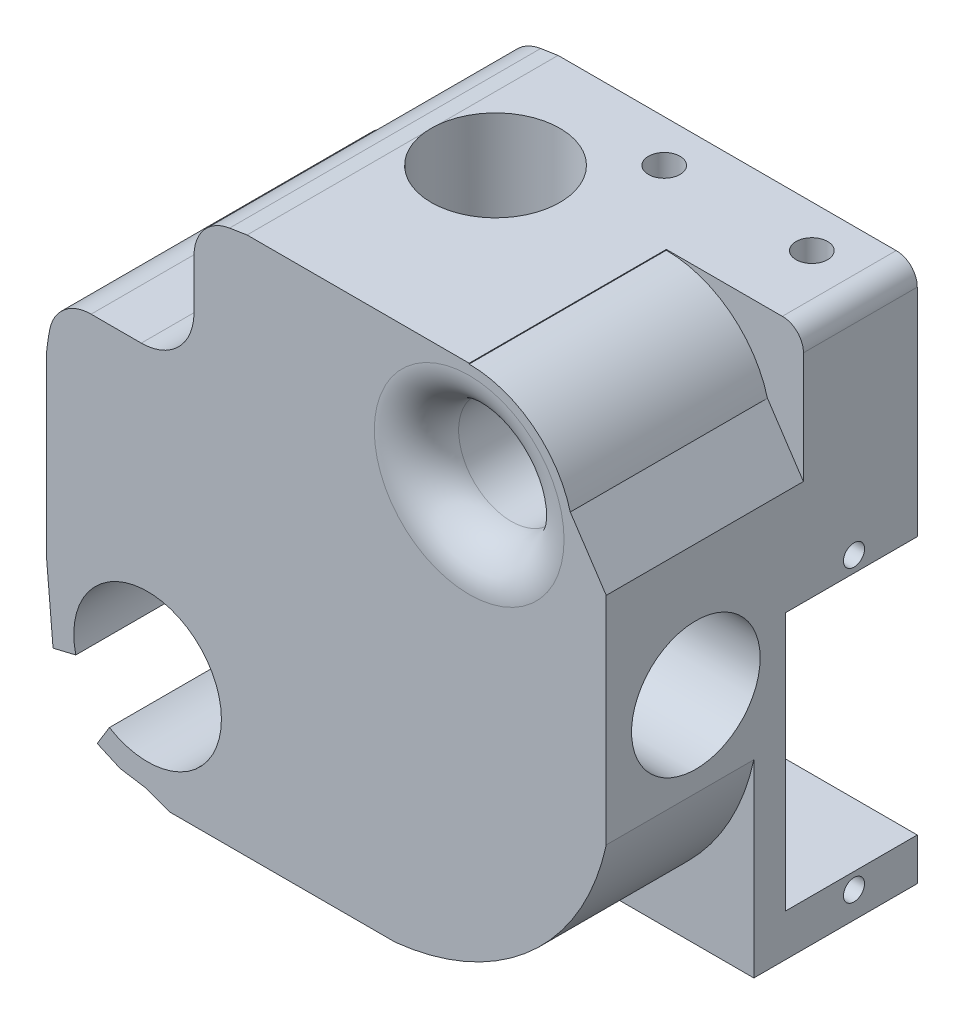
from build123d import *

# Parameters (mm, degrees)
SALIENTE_EXTRUIR1_DEPTH = 29.5
CORTAR_EXTRUIR11_DEPTH  = 18.7
CROQUIS12_W             = 20
CROQUIS12_H             = 28.5
SALIENTE_EXTRUIR2_DEPTH = 15.5
CROQUIS6_R              = 8.5
CORTAR_EXTRUIR1_DEPTH   = 10
CROQUIS7_R              = 4.1
CORTAR_EXTRUIR2_DEPTH   = 13.5
CROQUIS8_R              = 4.4
CORTAR_EXTRUIR3_DEPTH   = 6
CROQUIS2_R              = 6.1
CORTAR_EXTRUIR4_DEPTH   = 20
CROQUIS3_R              = 6.1
CORTAR_EXTRUIR5_DEPTH   = 20
CROQUIS4_R              = 6.1
CORTAR_EXTRUIR6_DEPTH   = 20
CROQUIS5_R              = 6.1
CORTAR_EXTRUIR7_DEPTH   = 20
CORTAR_EXTRUIR8_REACH   = 35.067
CROQUIS9_R              = 3.5
CORTAR_EXTRUIR9_REACH   = 33.068
CROQUIS10_R             = 3.5
CROQUIS13_W             = 20
CROQUIS13_H             = 24.5
CORTAR_EXTRUIR10_DEPTH  = 12.5
CORTAR_EXTRUIR12_START  = -10
CROQUIS18_R             = 1.5
CORTAR_EXTRUIR12_DEPTH  = 10
CROQUIS19_R             = 1
CORTAR_EXTRUIR13_DEPTH  = 10
CROQUIS20_R             = 2.1
CORTAR_EXTRUIR14_DEPTH  = 10
CROQUIS21_R             = 5
CORTAR_EXTRUIR15_DEPTH  = 50
CROQUIS23_W             = 16.524922623
CROQUIS23_H             = 14.423778161
CORTAR_EXTRUIR16_DEPTH  = 50
REDONDEO1_R             = 4
REDONDEO2_R             = 5
REDONDEO3_R             = 4


with BuildPart() as part:
    # Croquis1 → Saliente-Extruir1 (new body)
    with BuildSketch(Plane.XY):
        with BuildLine():
            Line((5.532260486, 11.858052865), (4.932758535, 18.779017183))
            Line((4.932758535, 18.779017183), (4.932758535, 36))
            ThreePointArc((4.932758535, 36), (10.243586381, 47.979347327), (21.538526154, 54.62268913))
            Line((21.538526154, 54.62268913), (23.932758535, 55))
            Line((23.932758535, 55), (56, 55))
            ThreePointArc((56, 55), (57.424264069, 54.424264069), (58, 53))
            Line((58, 53), (58, 21.932758535))
            ThreePointArc((58, 21.932758535), (50.913097547, 9.695983483), (38, 3.932758535))
            Line((38, 3.932758535), (16.641947135, 3.932758535))
            Line((16.641947135, 3.932758535), (14.26534365, 4.78116089))
            Line((14.26534365, 4.78116089), (11.904731608, 5.153727551))
            Line((11.904731608, 5.153727551), (9.720982817, 6.124570664))
            Line((9.720982817, 6.124570664), (10.875746205, 8.011278565))
            ThreePointArc((10.875746205, 8.011278565), (20.155175368, 18.125408047), (7.690637501, 12.377476547))
            Line((7.690637501, 12.377476547), (5.532260486, 11.858052865))
        make_face()
    extrude(amount=-SALIENTE_EXTRUIR1_DEPTH)

    # Croquis15 → Cortar-Extruir11 (cut)
    with BuildSketch(Plane.XY):
        with BuildLine():
            Line((58, 42.430465887), (58, 53))
            ThreePointArc((58, 53), (57.424264069, 54.424264069), (56, 55))
            Line((56, 55), (45, 55))
            Line((45, 55), (45, 54.927917446))
            ThreePointArc((45, 54.927917446), (51.043733212, 52.876346468), (54.589631863, 47.569534113))
            Line((54.589631863, 47.569534113), (58, 42.430465887))
        make_face()
    extrude(amount=-CORTAR_EXTRUIR11_DEPTH, mode=Mode.SUBTRACT)

    # Croquis12 → Saliente-Extruir2 (add)
    with BuildSketch(Plane(origin=(0, 0, -29.5), x_dir=(-1, 0, 0), z_dir=(0, 0, -1))):
        with Locations((-48, 18.25)):
            Rectangle(CROQUIS12_W, CROQUIS12_H)
    extrude(amount=-SALIENTE_EXTRUIR2_DEPTH)

    # Croquis6 → Cortar-Extruir1 (cut)
    with BuildSketch(Plane(origin=(0, 0, -29.5), x_dir=(-1, 0, 0), z_dir=(0, 0, -1))):
        with Locations((-45, 45)):
            Circle(CROQUIS6_R)
    extrude(amount=-CORTAR_EXTRUIR1_DEPTH, mode=Mode.SUBTRACT)

    # Croquis7 → Cortar-Extruir2 (cut)
    with BuildSketch(Plane(origin=(0, 0, -19.5), x_dir=(-1, 0, 0), z_dir=(0, 0, -1))):
        with Locations((-45, 45)):
            Circle(CROQUIS7_R)
    extrude(amount=-CORTAR_EXTRUIR2_DEPTH, mode=Mode.SUBTRACT)

    # Croquis8 → Cortar-Extruir3 (cut)
    with BuildSketch(Plane.XY):
        with Locations((45, 45)):
            Circle(CROQUIS8_R)
    extrude(amount=-CORTAR_EXTRUIR3_DEPTH, mode=Mode.SUBTRACT)

    # Croquis2 → Cortar-Extruir4 (cut)
    with BuildSketch(Plane.XZ.offset(-3.932758535)):
        with Locations((30, -17.5)):
            Circle(CROQUIS2_R)
    extrude(amount=-CORTAR_EXTRUIR4_DEPTH, mode=Mode.SUBTRACT)

    # Croquis3 → Cortar-Extruir5 (cut)
    with BuildSketch(Plane(origin=(0, 55, 0), x_dir=(1, 0, 0), z_dir=(0, 1, 0))):
        with Locations((30, 17.5)):
            Circle(CROQUIS3_R)
    extrude(amount=-CORTAR_EXTRUIR5_DEPTH, mode=Mode.SUBTRACT)

    # Croquis4 → Cortar-Extruir6 (cut)
    with BuildSketch(Plane.ZY.offset(-4.932758535)):
        with Locations((-8.5, 30)):
            Circle(CROQUIS4_R)
    extrude(amount=-CORTAR_EXTRUIR6_DEPTH, mode=Mode.SUBTRACT)

    # Croquis5 → Cortar-Extruir7 (cut)
    with BuildSketch(Plane(origin=(58, 0, 0), x_dir=(0, 0, -1), z_dir=(1, 0, 0))):
        with Locations((8.5, 30)):
            Circle(CROQUIS5_R)
    extrude(amount=-CORTAR_EXTRUIR7_DEPTH, mode=Mode.SUBTRACT)

    # Croquis9 → Cortar-Extruir8 (cut, up to next)
    with BuildSketch(Plane(origin=(38, 0, 0), x_dir=(0, 0, -1), z_dir=(1, 0, 0)), mode=Mode.PRIVATE) as cortar_extruir8_sk1:
        with Locations((8.5, 30)):
            Circle(CROQUIS9_R)
    cortar_extruir8_tool1 = extrude(cortar_extruir8_sk1.sketch, amount=-CORTAR_EXTRUIR8_REACH, mode=Mode.PRIVATE) & part.part
    add(cortar_extruir8_tool1.solids().sort_by_distance((38, 30, -8.5))[0], mode=Mode.SUBTRACT)

    # Croquis10 → Cortar-Extruir9 (cut, up to next)
    with BuildSketch(Plane.XZ.offset(-23.932758535), mode=Mode.PRIVATE) as cortar_extruir9_sk1:
        with Locations((30, -17.5)):
            Circle(CROQUIS10_R)
    cortar_extruir9_tool1 = extrude(cortar_extruir9_sk1.sketch, amount=-CORTAR_EXTRUIR9_REACH, mode=Mode.PRIVATE) & part.part
    add(cortar_extruir9_tool1.solids().sort_by_distance((30, 23.932759, -17.5))[0], mode=Mode.SUBTRACT)

    # Croquis13 → Cortar-Extruir10 (cut)
    with BuildSketch(Plane(origin=(0, 0, -29.5), x_dir=(-1, 0, 0), z_dir=(0, 0, -1))):
        with Locations((-48, 20.25)):
            Rectangle(CROQUIS13_W, CROQUIS13_H)
    extrude(amount=-CORTAR_EXTRUIR10_DEPTH, mode=Mode.SUBTRACT)

    # Croquis18 → Cortar-Extruir12 (cut)
    with BuildSketch(Plane(origin=(0, 55, 0), x_dir=(1, 0, 0), z_dir=(0, 1, 0)).offset(CORTAR_EXTRUIR12_START)):
        with Locations((38.000000773, 25.50000943)):
            Circle(CROQUIS18_R)
        with Locations((52.000000773, 25.50000943)):
            Circle(CROQUIS18_R)
    extrude(amount=CORTAR_EXTRUIR12_DEPTH, mode=Mode.SUBTRACT)

    # Croquis19 → Cortar-Extruir13 (cut)
    with BuildSketch(Plane(origin=(58, 0, 0), x_dir=(0, 0, -1), z_dir=(1, 0, 0))):
        with Locations((23.5, 34)):
            Circle(CROQUIS19_R)
        with Locations((23.5, 6.5)):
            Circle(CROQUIS19_R)
    extrude(amount=-CORTAR_EXTRUIR13_DEPTH, mode=Mode.SUBTRACT)

    # Croquis20 → Cortar-Extruir14 (cut)
    with BuildSketch(Plane(origin=(0, 0, -29.5), x_dir=(-1, 0, 0), z_dir=(0, 0, -1))):
        with Locations((-16, 36)):
            Circle(CROQUIS20_R)
    extrude(amount=-CORTAR_EXTRUIR14_DEPTH, mode=Mode.SUBTRACT)

    # Croquis21 → Cortar-Extruir15 (cut)
    with BuildSketch(Plane.XY):
        with Locations((45, 45)):
            Circle(CROQUIS21_R)
    extrude(amount=-CORTAR_EXTRUIR15_DEPTH, mode=Mode.SUBTRACT)

    # Croquis23 → Cortar-Extruir16 (cut)
    with BuildSketch(Plane.XY):
        with Locations((10.637538689, 48.311889081)):
            Rectangle(CROQUIS23_W, CROQUIS23_H)
    extrude(amount=-CORTAR_EXTRUIR16_DEPTH, mode=Mode.SUBTRACT)

    # Redondeo1
    redondeo1_edges = [part.edges().sort_by_distance(p)[0] for p in [
        (6.121220744, 41.1, -14.75),
        (18.9, 53.849676427, -14.75),
    ]]
    fillet(redondeo1_edges, radius=REDONDEO1_R)

    # Redondeo2
    redondeo2_edges = [part.edges().sort_by_distance(p)[0] for p in [
        (18.9, 41.1, -14.75),
    ]]
    fillet(redondeo2_edges, radius=REDONDEO2_R)

    # Redondeo3
    redondeo3_edges = [part.edges().sort_by_distance(p)[0] for p in [
        (40, 45, 0),
    ]]
    fillet(redondeo3_edges, radius=REDONDEO3_R)


solid = part.part
